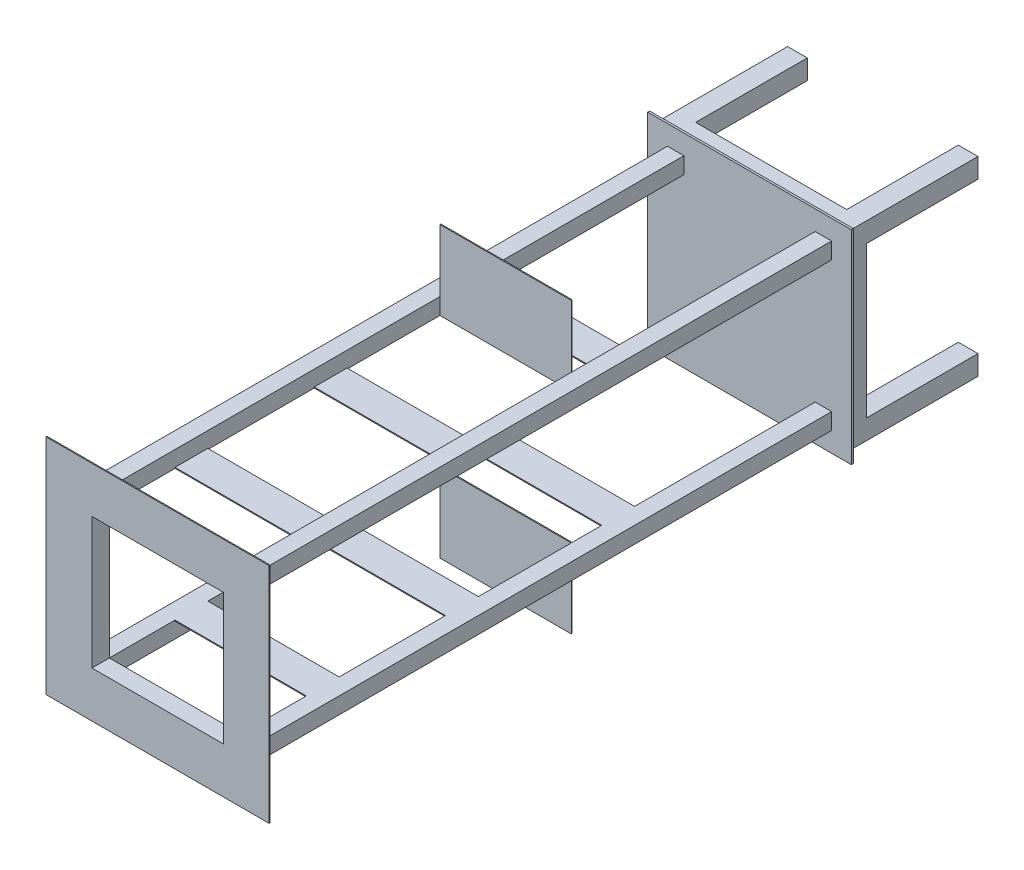
from build123d import *

# Parameters (mm, degrees)
SKETCH_1_W        = 30
SKETCH_1_H        = 30
SKETCH_1_W_2      = 26
SKETCH_1_H_2      = 26
EXTRUDE_1_DEPTH   = 200
EXTRUDE_1_2_DEPTH = 200
EXTRUDE_1_3_DEPTH = 200
EXTRUDE_1_4_DEPTH = 200
SKETCH_2_W        = 310
SKETCH_2_H        = 310
EXTRUDE_2_DEPTH   = 3
SKETCH_5_W        = 25
SKETCH_5_H        = 25
SKETCH_5_W_2      = 22
SKETCH_5_H_2      = 22
EXTRUDE_3_DEPTH   = 900
SKETCH_6_W        = 340
SKETCH_6_H        = 340
SKETCH_6_W_2      = 200
SKETCH_6_H_2      = 200
EXTRUDE_4_DEPTH   = 1.5
SKETCH_7_W        = 200
SKETCH_7_H        = 120
EXTRUDE_5_DEPTH   = 1.5
SKETCH_8_W        = 200
SKETCH_8_H        = 1.5
EXTRUDE_6_DEPTH   = 25
SKETCH_9_W        = 200
SKETCH_9_H        = 1.5
EXTRUDE_7_DEPTH   = 25
SKETCH_11_W       = 200
SKETCH_11_H       = 1.5
EXTRUDE_8_DEPTH   = 25
SKETCH_12_W       = 30
SKETCH_12_H       = 30
EXTRUDE_9_DEPTH   = 230
SKETCH_13_W       = 30
SKETCH_13_H       = 30
EXTRUDE_10_DEPTH  = 230
SKETCH_14_W       = 25
SKETCH_14_H       = 25
EXTRUDE_11_DEPTH  = 220
SKETCH_15_W       = 25
SKETCH_15_H       = 25
EXTRUDE_12_DEPTH  = 220


with BuildPart() as part:
    # 草圖1 → 填料-伸長1 (new body)
    with BuildSketch(Plane.XY):
        with Locations((-83.068744212, 102.787427317)):
            Rectangle(SKETCH_1_W, SKETCH_1_H)
        with Locations((-83.068744212, 102.787427317)):
            Rectangle(SKETCH_1_W_2, SKETCH_1_H_2, mode=Mode.SUBTRACT)
    extrude(amount=EXTRUDE_1_DEPTH)



with BuildPart() as body_2:
    # 草圖1 → Extrude 1 2 (new body)
    with BuildSketch(Plane.XY):
        with Locations((176.931255788, 102.787427317)):
            Rectangle(SKETCH_1_W, SKETCH_1_H)
        with Locations((176.931255788, 102.787427317)):
            Rectangle(SKETCH_1_W_2, SKETCH_1_H_2, mode=Mode.SUBTRACT)
    extrude(amount=EXTRUDE_1_2_DEPTH)


with BuildPart() as body_3:
    # 草圖1 → Extrude 1 3 (new body)
    with BuildSketch(Plane.XY):
        with Locations((-83.068744212, -157.212572683)):
            Rectangle(SKETCH_1_W, SKETCH_1_H)
        with Locations((-83.068744212, -157.212572683)):
            Rectangle(SKETCH_1_W_2, SKETCH_1_H_2, mode=Mode.SUBTRACT)
    extrude(amount=EXTRUDE_1_3_DEPTH)


with BuildPart() as body_4:
    # 草圖1 → Extrude 1 4 (new body)
    with BuildSketch(Plane.XY):
        with Locations((176.931255788, -157.212572683)):
            Rectangle(SKETCH_1_W, SKETCH_1_H)
        with Locations((176.931255788, -157.212572683)):
            Rectangle(SKETCH_1_W_2, SKETCH_1_H_2, mode=Mode.SUBTRACT)
    extrude(amount=EXTRUDE_1_4_DEPTH)


with BuildPart() as part_1:
    add(part.part)

    add(body_2.part)  # 填料-伸長2 merges body 2

    add(body_3.part)  # 填料-伸長2 merges body 3

    add(body_4.part)  # 填料-伸長2 merges body 4
    # 草圖2 → 填料-伸長2 (add)
    with BuildSketch(Plane.XY.offset(200)):
        with Locations((46.931255788, -27.212572683)):
            Rectangle(SKETCH_2_W, SKETCH_2_H)
    extrude(amount=EXTRUDE_2_DEPTH)

    # 草圖5 → 填料-伸長3 (add)
    with BuildSketch(Plane.XY.offset(203)):
        with Locations((-65.568744212, 85.287427317)):
            Rectangle(SKETCH_5_W, SKETCH_5_H)
        with Locations((-65.568744212, 85.287427317)):
            Rectangle(SKETCH_5_W_2, SKETCH_5_H_2, mode=Mode.SUBTRACT)
        with Locations((-65.568744212, -139.712572683)):
            Rectangle(SKETCH_5_W, SKETCH_5_H)
        with Locations((-65.568744212, -139.712572683)):
            Rectangle(SKETCH_5_W_2, SKETCH_5_H_2, mode=Mode.SUBTRACT)
        with Locations((159.431255788, -139.712572683)):
            Rectangle(SKETCH_5_W, SKETCH_5_H)
        with Locations((159.431255788, -139.712572683)):
            Rectangle(SKETCH_5_W_2, SKETCH_5_H_2, mode=Mode.SUBTRACT)
        with Locations((159.431255788, 85.287427317)):
            Rectangle(SKETCH_5_W, SKETCH_5_H)
        with Locations((159.431255788, 85.287427317)):
            Rectangle(SKETCH_5_W_2, SKETCH_5_H_2, mode=Mode.SUBTRACT)
    extrude(amount=EXTRUDE_3_DEPTH)

    # 草圖6 → 填料-伸長4 (add)
    with BuildSketch(Plane.XY.offset(1103)):
        with Locations((46.931255788, -27.212572683)):
            Rectangle(SKETCH_6_W, SKETCH_6_H)
        with Locations((46.931255788, -27.212572683)):
            Rectangle(SKETCH_6_W_2, SKETCH_6_H_2, mode=Mode.SUBTRACT)
    extrude(amount=EXTRUDE_4_DEPTH)

    # 草圖7 → 填料-伸長5 (add)
    with BuildSketch(Plane.XY.offset(573)):
        with Locations((46.931255788, 132.787427317)):
            Rectangle(SKETCH_7_W, SKETCH_7_H)
        with Locations((46.931255788, -187.212572683)):
            Rectangle(SKETCH_7_W, SKETCH_7_H)
    extrude(amount=EXTRUDE_5_DEPTH)

    # 草圖8 → 填料-伸長6 (add, symmetric)
    with BuildSketch(Plane(origin=(0, 0, 953), x_dir=(-1, 0, 0), z_dir=(0, 0, -1))):
        with Locations((-46.931255788, 73.537427317)):
            Rectangle(SKETCH_8_W, SKETCH_8_H)
        with Locations((-46.931255788, -127.962572683)):
            Rectangle(SKETCH_8_W, SKETCH_8_H)
    extrude(amount=EXTRUDE_6_DEPTH, both=True)

    # 草圖9 → 填料-伸長7 (add, symmetric)
    with BuildSketch(Plane(origin=(0, 0, 741), x_dir=(-1, 0, 0), z_dir=(0, 0, -1))):
        with Locations((-46.931255788, 73.537427317)):
            Rectangle(SKETCH_9_W, SKETCH_9_H)
        with Locations((-46.931255788, -127.962572683)):
            Rectangle(SKETCH_9_W, SKETCH_9_H)
    extrude(amount=EXTRUDE_7_DEPTH, both=True)

    # 草圖11 → 填料-伸長8 (add, symmetric)
    with BuildSketch(Plane(origin=(0, 0, 503), x_dir=(-1, 0, 0), z_dir=(0, 0, -1))):
        with Locations((-46.931255788, -127.962572683)):
            Rectangle(SKETCH_11_W, SKETCH_11_H)
        with Locations((-46.931255788, 73.537427317)):
            Rectangle(SKETCH_11_W, SKETCH_11_H)
    extrude(amount=EXTRUDE_8_DEPTH, both=True)

    # 草圖12 → 填料-伸長9 (add)
    with BuildSketch(Plane(origin=(-68.068744212, 0, 0), x_dir=(0, 0, -1), z_dir=(1, 0, 0))):
        with Locations((-185, 102.787427317)):
            Rectangle(SKETCH_12_W, SKETCH_12_H)
        with Locations((-185, -157.212572683)):
            Rectangle(SKETCH_12_W, SKETCH_12_H)
    extrude(amount=EXTRUDE_9_DEPTH)

    # 草圖13 → 填料-伸長10 (add)
    with BuildSketch(Plane(origin=(0, -142.212572683, 0), x_dir=(1, 0, 0), z_dir=(0, 1, 0))):
        with Locations((-83.068744212, -185)):
            Rectangle(SKETCH_13_W, SKETCH_13_H)
        with Locations((176.931255788, -185)):
            Rectangle(SKETCH_13_W, SKETCH_13_H)
    extrude(amount=EXTRUDE_10_DEPTH)

    # 草圖14 → 填料-伸長11 (add)
    with BuildSketch(Plane(origin=(0, -127.212572683, 0), x_dir=(1, 0, 0), z_dir=(0, 1, 0))):
        with Locations((-65.568744212, -1090.5)):
            Rectangle(SKETCH_14_W, SKETCH_14_H)
        with Locations((159.431255788, -1090.5)):
            Rectangle(SKETCH_14_W, SKETCH_14_H)
    extrude(amount=EXTRUDE_11_DEPTH)

    # 草圖15 → 填料-伸長12 (add)
    with BuildSketch(Plane(origin=(-53.068744212, 0, 0), x_dir=(0, 0, -1), z_dir=(1, 0, 0))):
        with Locations((-1090.5, 85.287427317)):
            Rectangle(SKETCH_15_W, SKETCH_15_H)
        with Locations((-1090.5, -139.712572683)):
            Rectangle(SKETCH_15_W, SKETCH_15_H)
    extrude(amount=EXTRUDE_12_DEPTH)


solid = part_1.part
